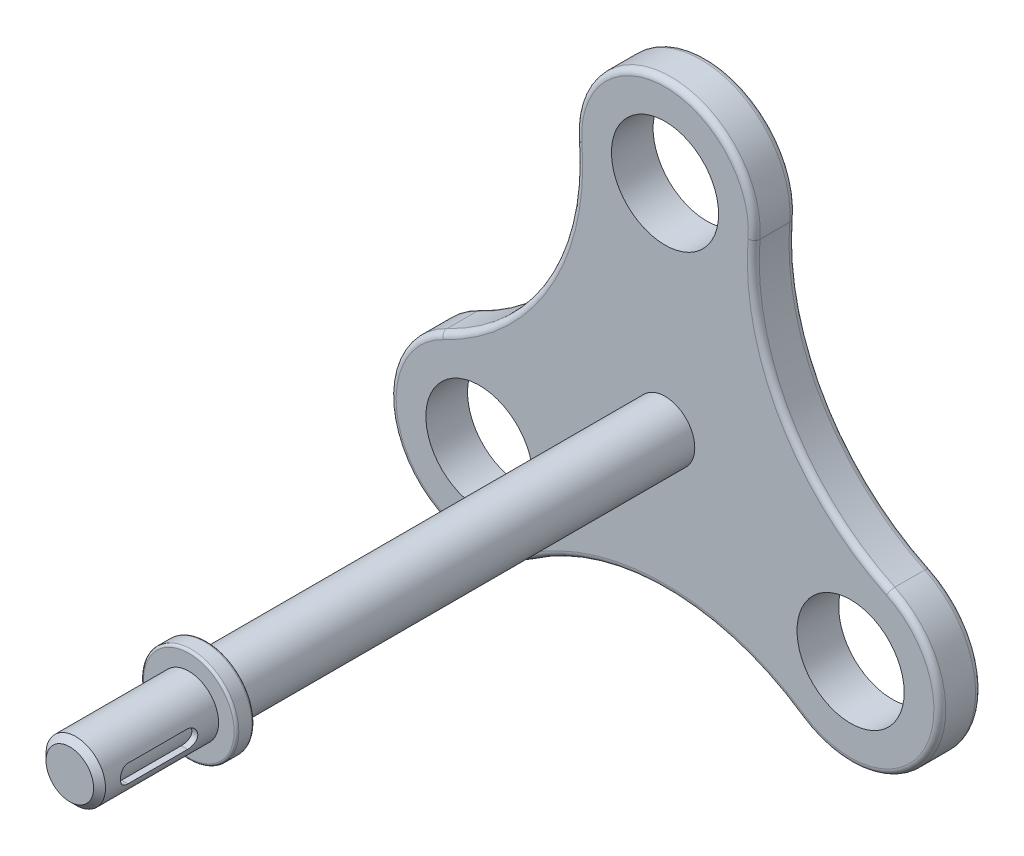
from build123d import *

# Parameters (mm, degrees)
SKETCH1_R               = 7.5
SKETCH1_R_2             = 4.5
BOSS_EXTRUDE1_DEPTH     = 3.5
SKETCH3_R               = 2.5
BOSS_EXTRUDE2_DEPTH     = 50
BOSS_EXTRUDE3_START     = -10
SKETCH4_R               = 4
BOSS_EXTRUDE3_DEPTH     = 1.5
CUT_EXTRUDE1_REACH      = 70.605
CUT_EXTRUDE1_END_RADIUS = 2
CUT_EXTRUDE1_START      = 5
CHAMFER1_SIZE           = 0.5
FILLET1_R               = 0.2
FILLET2_R               = 0.5


with BuildPart() as part:
    # Sketch1 → Boss-Extrude1 (new body)
    with BuildSketch(Plane.XY):
        with Locations((0, 18)):
            Circle(SKETCH1_R)
        with Locations((0, 18)):
            Circle(SKETCH1_R_2, mode=Mode.SUBTRACT)
        with Locations((-15.588457268, -9)):
            Circle(SKETCH1_R)
        with Locations((-15.588457268, -9)):
            Circle(SKETCH1_R_2, mode=Mode.SUBTRACT)
        with Locations((15.588457268, -9)):
            Circle(SKETCH1_R)
        with Locations((15.588457268, -9)):
            Circle(SKETCH1_R_2, mode=Mode.SUBTRACT)
        with BuildLine():
            ThreePointArc((7.476559852, 17.407502934), (0, 10.5), (-7.476559852, 17.407502934))
            ThreePointArc((-7.476559852, 17.407502934), (-10.093544717, 5.827510759), (-18.813619684, -2.228860702))
            ThreePointArc((-18.813619684, -2.228860702), (-11.584628982, -2.658126534), (-8.088457268, -9))
            ThreePointArc((-8.088457268, -9), (-8.950103527, -12.490309386), (-11.337059831, -15.178642232))
            ThreePointArc((-11.337059831, -15.178642232), (0, -11.655021518), (11.337059831, -15.178642232))
            ThreePointArc((11.337059831, -15.178642232), (9.09326674, -5.25), (18.813619684, -2.228860702))
            ThreePointArc((18.813619684, -2.228860702), (10.093544717, 5.827510759), (7.476559852, 17.407502934))
        make_face()
    extrude(amount=BOSS_EXTRUDE1_DEPTH)

    # Sketch3 → Boss-Extrude2 (add)
    with BuildSketch(Plane.XY.offset(3.5)):
        Circle(SKETCH3_R)
    extrude(amount=BOSS_EXTRUDE2_DEPTH)

    # Sketch4 → Boss-Extrude3 (add)
    with BuildSketch(Plane.XY.offset(53.5).offset(BOSS_EXTRUDE3_START)):
        Circle(SKETCH4_R)
    extrude(amount=-BOSS_EXTRUDE3_DEPTH)

    # Cut-Extrude1: up to this cylinder (the profile starts outside it)
    cut_extrude1_end = Plane(origin=(0, 0, 48.5), z_dir=(0, 0, -1)) * Cylinder(CUT_EXTRUDE1_END_RADIUS, 146.21, mode=Mode.PRIVATE)
    # Sketch6 → Cut-Extrude1 (cut, up to the surface)
    with BuildSketch(Plane(origin=(0, 0, 0), x_dir=(0, 0, -1), z_dir=(1, 0, 0)).offset(CUT_EXTRUDE1_START), mode=Mode.PRIVATE) as cut_extrude1_sk1:
        with BuildLine():
            Line((-46, -0.75), (-51, -0.75))
            ThreePointArc((-51, -0.75), (-51.75, 0), (-51, 0.75))
            Line((-51, 0.75), (-46, 0.75))
            ThreePointArc((-46, 0.75), (-45.25, 0), (-46, -0.75))
        make_face()
    cut_extrude1_tool1 = extrude(cut_extrude1_sk1.sketch, amount=-CUT_EXTRUDE1_REACH, mode=Mode.PRIVATE) - cut_extrude1_end
    add(cut_extrude1_tool1.solids().sort_by_distance((5, 0, 48.5))[0], mode=Mode.SUBTRACT)

    # Chamfer1
    chamfer1_edges = [part.edges().sort_by_distance(p)[0] for p in [
        (-2.5, 0, 53.5),
    ]]
    chamfer(chamfer1_edges, length=CHAMFER1_SIZE)

    # Fillet1
    fillet1_edges = [part.edges().sort_by_distance(p)[0] for p in [
        (-4, 0, 42),
        (-4, 0, 43.5),
    ]]
    fillet(fillet1_edges, radius=FILLET1_R)

    # Fillet2
    fillet2_edges = [part.edges().sort_by_distance(p)[0] for p in [
        (10.093544717, 5.827510759, 0),
        (22.083647797, -12.75, 0),
        (0, 25.5, 3.5),
        (0, -11.655021518, 0),
        (-22.083647797, -12.75, 0),
        (-10.093544717, 5.827510759, 0),
        (0, 25.5, 0),
        (-10.093544717, 5.827510759, 3.5),
        (-22.083647797, -12.75, 3.5),
        (0, -11.655021518, 3.5),
        (22.083647797, -12.75, 3.5),
        (10.093544717, 5.827510759, 3.5),
    ]]
    fillet(fillet2_edges, radius=FILLET2_R)


solid = part.part
